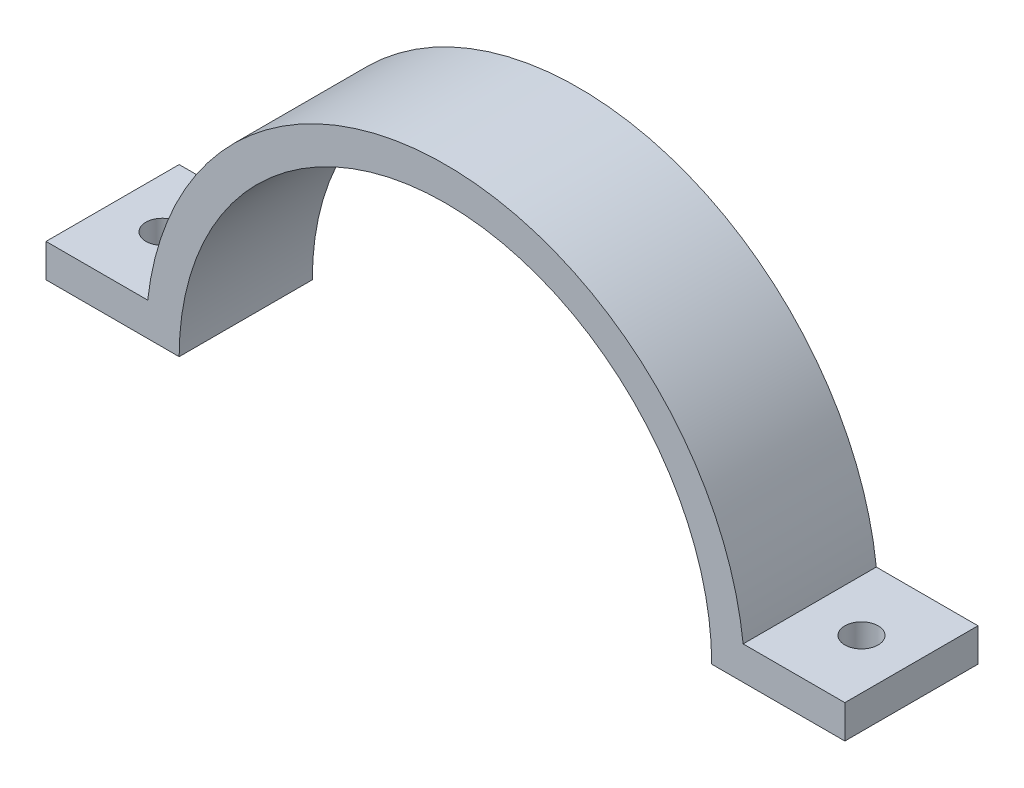
from build123d import *

# Parameters (mm, degrees)
BOSS_EXTRUDE1_DEPTH = 20
SKETCH3_R           = 2.5
CUT_EXTRUDE2_DEPTH  = 6


with BuildPart() as part:
    # Sketch1 → Boss-Extrude1 (new body)
    with BuildSketch(Plane.XY):
        with BuildLine():
            Line((-45, 0), (-40, 0))
            ThreePointArc((-40, 0), (0, 40), (40, 0))
            Line((40, 0), (45, 0))
            Line((45, 0), (60, 0))
            Line((60, 0), (60, 5))
            Line((60, 5), (44.72135955, 5))
            ThreePointArc((44.72135955, 5), (0, 45), (-44.72135955, 5))
            Line((-44.72135955, 5), (-60, 5))
            Line((-60, 5), (-60, 0))
            Line((-60, 0), (-45, 0))
        make_face()
    extrude(amount=BOSS_EXTRUDE1_DEPTH)

    # Sketch3 → Cut-Extrude2 (cut, through all)
    with BuildSketch(Plane(origin=(0, 5, 0), x_dir=(1, 0, 0), z_dir=(0, 1, 0))):
        with Locations((-52.5, -10)):
            Circle(SKETCH3_R)
        with Locations((52.5, -10)):
            Circle(SKETCH3_R)
    extrude(amount=-CUT_EXTRUDE2_DEPTH, mode=Mode.SUBTRACT)


solid = part.part
